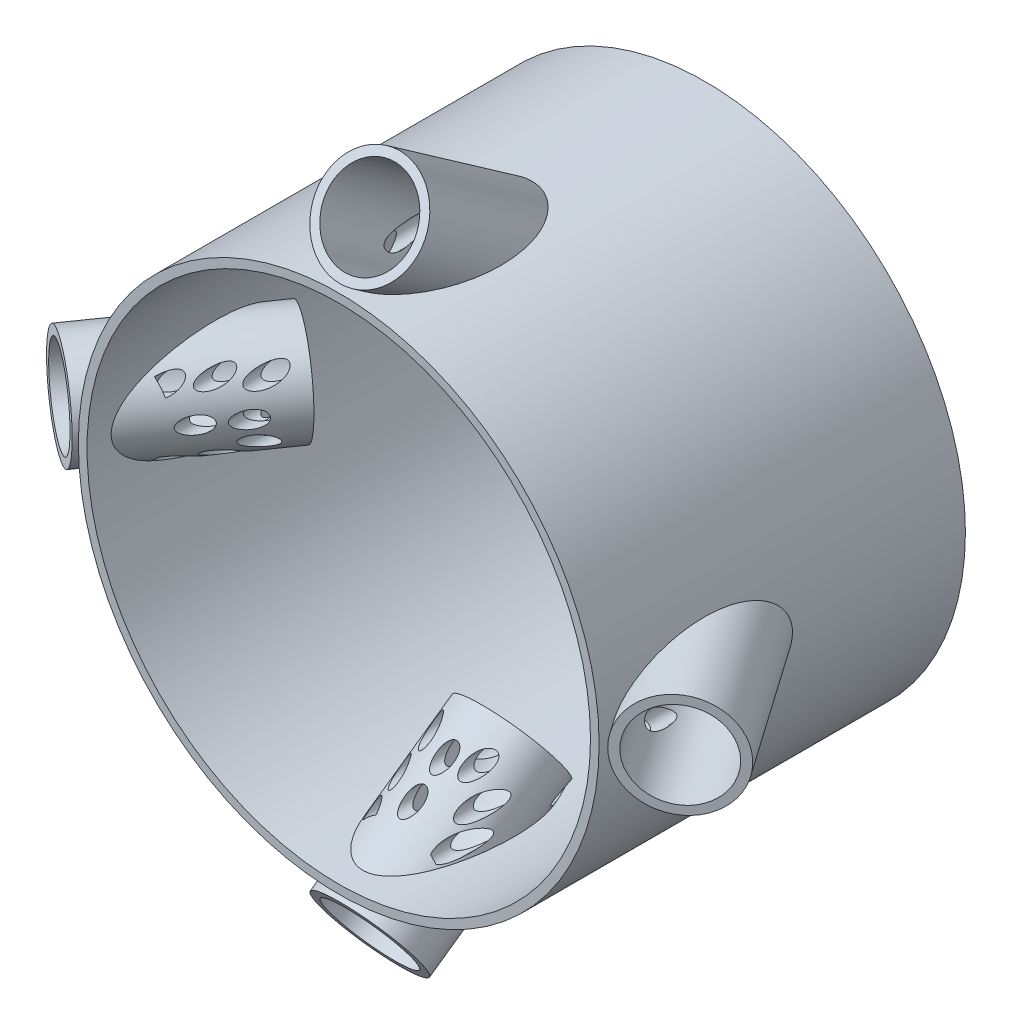
from build123d import *

# Parameters (mm, degrees)
SKETCH2_R                = 300
SKETCH2_R_2              = 290
BOSS_EXTRUDE1_DEPTH      = 405
BOSS_EXTRUDE1_DEPTH_BACK = 17
SKETCH7_R                = 60
SKETCH7_R_2              = 50
BOSS_EXTRUDE2_DEPTH      = 320
SKETCH8_R                = 60
SKETCH8_R_2              = 50
CUT_EXTRUDE1_DEPTH       = 120
SKETCH9_R                = 50
CUT_EXTRUDE2_DEPTH       = 1650
SKETCH10_R               = 60
SKETCH10_R_2             = 50
BOSS_EXTRUDE3_DEPTH      = 320
SKETCH16_R               = 60
SKETCH16_R_2             = 50
BOSS_EXTRUDE4_DEPTH      = 320
SKETCH17_R               = 60
SKETCH17_R_2             = 50
CUT_EXTRUDE3_DEPTH       = 120
SKETCH18_R               = 50
CUT_EXTRUDE4_DEPTH       = 600
SKETCH19_R               = 50
CUT_EXTRUDE5_DEPTH       = 600
SKETCH20_R               = 60
SKETCH20_R_2             = 50
BOSS_EXTRUDE5_DEPTH      = 320
SKETCH21_R               = 60
SKETCH21_R_2             = 50
BOSS_EXTRUDE6_DEPTH      = 120
SKETCH22_R               = 50
CUT_EXTRUDE6_DEPTH       = 733
SKETCH23_R               = 60
SKETCH23_R_2             = 50
CUT_EXTRUDE7_DEPTH       = 120
SKETCH24_R               = 60
SKETCH24_R_2             = 50
CUT_EXTRUDE8_DEPTH       = 120
SKETCH25_R               = 10
SKETCH25_R_2             = 8.952024114
CUT_EXTRUDE9_DEPTH       = 336


with BuildPart() as part:
    # Sketch2 → Boss-Extrude1 (new body, two sides)
    with BuildSketch(Plane.XY) as boss_extrude1_sk:
        Circle(SKETCH2_R)
        Circle(SKETCH2_R_2, mode=Mode.SUBTRACT)
    extrude(amount=BOSS_EXTRUDE1_DEPTH)
    extrude(boss_extrude1_sk.sketch, amount=-BOSS_EXTRUDE1_DEPTH_BACK)

    # Sketch7 → Boss-Extrude2 (add)
    with BuildSketch(Plane(origin=(-107.600608248, 0, 153.669594193), x_dir=(0.819152044, 0, 0.573576436), z_dir=(-0.573576436, 0, 0.819152044))):
        with Locations((-81.211008345, 0)):
            Circle(SKETCH7_R)
        with Locations((-81.211008345, 0)):
            Circle(SKETCH7_R_2, mode=Mode.SUBTRACT)
    extrude(amount=BOSS_EXTRUDE2_DEPTH)

    # Sketch8 → Cut-Extrude1 (cut)
    with BuildSketch(Plane(origin=(-107.600608248, 0, 153.669594193), x_dir=(0.819152044, 0, 0.573576436), z_dir=(-0.573576436, 0, 0.819152044))):
        with Locations((-81.211008345, 0)):
            Circle(SKETCH8_R)
        with Locations((-81.211008345, 0)):
            Circle(SKETCH8_R_2, mode=Mode.SUBTRACT)
    extrude(amount=CUT_EXTRUDE1_DEPTH, mode=Mode.SUBTRACT)

    # Sketch9 → Cut-Extrude2 (cut)
    with BuildSketch(Plane(origin=(-107.600608248, 0, 153.669594193), x_dir=(0.819152044, 0, 0.573576436), z_dir=(-0.573576436, 0, 0.819152044))):
        with Locations((-81.211008345, 0)):
            Circle(SKETCH9_R)
    extrude(amount=CUT_EXTRUDE2_DEPTH, mode=Mode.SUBTRACT)

    # Sketch10 → Boss-Extrude3 (add)
    with BuildSketch(Plane(origin=(107.600608248, 0, 153.669594193), x_dir=(-0.819152044, 0, 0.573576436), z_dir=(-0.573576436, 0, -0.819152044))):
        with Locations((-81.211008345, 0)):
            Circle(SKETCH10_R)
        with Locations((-81.211008345, 0)):
            Circle(SKETCH10_R_2, mode=Mode.SUBTRACT)
    extrude(amount=-BOSS_EXTRUDE3_DEPTH)

    # Sketch16 → Boss-Extrude4 (add)
    with BuildSketch(Plane(origin=(0, -107.600608369, 153.669594367), x_dir=(0, 0.819152044, 0.573576436), z_dir=(0, 0.573576436, -0.819152044))):
        with Locations((-81.211008196, 0)):
            Circle(SKETCH16_R)
        with Locations((-81.211008196, 0)):
            Circle(SKETCH16_R_2, mode=Mode.SUBTRACT)
    extrude(amount=-BOSS_EXTRUDE4_DEPTH)

    # Sketch17 → Cut-Extrude3 (cut)
    with BuildSketch(Plane(origin=(0, -107.600608369, 153.669594367), x_dir=(0, 0.819152044, 0.573576436), z_dir=(0, 0.573576436, -0.819152044))):
        with Locations((-81.211008196, 0)):
            Circle(SKETCH17_R)
        with Locations((-81.211008196, 0)):
            Circle(SKETCH17_R_2, mode=Mode.SUBTRACT)
    extrude(amount=-CUT_EXTRUDE3_DEPTH, mode=Mode.SUBTRACT)

    # Sketch18 → Cut-Extrude4 (cut)
    with BuildSketch(Plane(origin=(0, -107.600608369, 153.669594367), x_dir=(0, 0.819152044, 0.573576436), z_dir=(0, 0.573576436, -0.819152044))):
        with Locations((-81.211008196, 0)):
            Circle(SKETCH18_R)
    extrude(amount=-CUT_EXTRUDE4_DEPTH, mode=Mode.SUBTRACT)

    # Sketch19 → Cut-Extrude5 (cut)
    with BuildSketch(Plane(origin=(107.600608248, 0, 153.669594193), x_dir=(-0.819152044, 0, 0.573576436), z_dir=(-0.573576436, 0, -0.819152044))):
        with Locations((-81.211008345, 0)):
            Circle(SKETCH19_R)
    extrude(amount=-CUT_EXTRUDE5_DEPTH, mode=Mode.SUBTRACT)

    # Sketch20 → Boss-Extrude5 (add)
    with BuildSketch(Plane(origin=(0, 107.600608369, 153.669594367), x_dir=(0, -0.819152044, 0.573576436), z_dir=(0, 0.573576436, 0.819152044))):
        with Locations((-81.211008196, 0)):
            Circle(SKETCH20_R)
        with Locations((-81.211008196, 0)):
            Circle(SKETCH20_R_2, mode=Mode.SUBTRACT)
    extrude(amount=BOSS_EXTRUDE5_DEPTH)

    # Sketch21 → Boss-Extrude6 (add)
    with BuildSketch(Plane(origin=(0, 107.600608369, 153.669594367), x_dir=(0, -0.819152044, 0.573576436), z_dir=(0, 0.573576436, 0.819152044))):
        with Locations((-81.211008196, 0)):
            Circle(SKETCH21_R)
        with Locations((-81.211008196, 0)):
            Circle(SKETCH21_R_2, mode=Mode.SUBTRACT)
    extrude(amount=BOSS_EXTRUDE6_DEPTH)

    # Sketch22 → Cut-Extrude6 (cut)
    with BuildSketch(Plane(origin=(0, 107.600608369, 153.669594367), x_dir=(0, -0.819152044, 0.573576436), z_dir=(0, 0.573576436, 0.819152044))):
        with Locations((-81.211008196, 0)):
            Circle(SKETCH22_R)
    extrude(amount=CUT_EXTRUDE6_DEPTH, mode=Mode.SUBTRACT)

    # Sketch23 → Cut-Extrude7 (cut)
    with BuildSketch(Plane(origin=(0, 107.600608369, 153.669594367), x_dir=(0, -0.819152044, 0.573576436), z_dir=(0, 0.573576436, 0.819152044))):
        with Locations((-81.211008196, 0)):
            Circle(SKETCH23_R)
        with Locations((-81.211008196, 0)):
            Circle(SKETCH23_R_2, mode=Mode.SUBTRACT)
    extrude(amount=CUT_EXTRUDE7_DEPTH, mode=Mode.SUBTRACT)

    # Sketch24 → Cut-Extrude8 (cut)
    with BuildSketch(Plane(origin=(107.600608248, 0, 153.669594193), x_dir=(-0.819152044, 0, 0.573576436), z_dir=(-0.573576436, 0, -0.819152044))):
        with Locations((-81.211008345, 0)):
            Circle(SKETCH24_R)
        with Locations((-81.211008345, 0)):
            Circle(SKETCH24_R_2, mode=Mode.SUBTRACT)
    extrude(amount=-CUT_EXTRUDE8_DEPTH, mode=Mode.SUBTRACT)

    # Sketch25 → Cut-Extrude9 (cut)
    with BuildSketch(Plane.XY):
        with Locations((0, 250.097173682)):
            Circle(SKETCH25_R)
        with Locations((36.92709947, 250.097173682)):
            Circle(SKETCH25_R_2)
        with Locations((-43.641117555, 250.097173682)):
            Circle(SKETCH25_R)
        with Locations((-26.856072342, 224.360104354)):
            Circle(SKETCH25_R)
        with Locations((-46.519733643, 273.994450106)):
            Circle(SKETCH25_R)
        with Locations((1, 276.683248051)):
            Circle(SKETCH25_R_2)
        with Locations((34.434879857, 273.994450106)):
            Circle(SKETCH25_R)
        with Locations((34.434879857, 224.360104354)):
            Circle(SKETCH25_R)
        with Locations((0, 224.360104354)):
            Circle(SKETCH25_R)
        with Locations((250.097173682, 0)):
            Circle(SKETCH25_R)
        with Locations((250.097173682, -36.92709947)):
            Circle(SKETCH25_R_2)
        with Locations((250.097173682, 43.641117555)):
            Circle(SKETCH25_R)
        with Locations((224.360104354, 26.856072342)):
            Circle(SKETCH25_R)
        with Locations((273.994450106, 46.519733643)):
            Circle(SKETCH25_R)
        with Locations((276.683248051, -1)):
            Circle(SKETCH25_R_2)
        with Locations((273.994450106, -34.434879857)):
            Circle(SKETCH25_R)
        with Locations((224.360104354, -34.434879857)):
            Circle(SKETCH25_R)
        with Locations((224.360104354, 0)):
            Circle(SKETCH25_R)
        with Locations((0, -250.097173682)):
            Circle(SKETCH25_R)
        with Locations((-36.92709947, -250.097173682)):
            Circle(SKETCH25_R_2)
        with Locations((43.641117555, -250.097173682)):
            Circle(SKETCH25_R)
        with Locations((26.856072342, -224.360104354)):
            Circle(SKETCH25_R)
        with Locations((46.519733643, -273.994450106)):
            Circle(SKETCH25_R)
        with Locations((-1, -276.683248051)):
            Circle(SKETCH25_R_2)
        with Locations((-34.434879857, -273.994450106)):
            Circle(SKETCH25_R)
        with Locations((-34.434879857, -224.360104354)):
            Circle(SKETCH25_R)
        with Locations((0, -224.360104354)):
            Circle(SKETCH25_R)
        with Locations((-250.097173682, 0)):
            Circle(SKETCH25_R)
        with Locations((-250.097173682, 36.92709947)):
            Circle(SKETCH25_R_2)
        with Locations((-250.097173682, -43.641117555)):
            Circle(SKETCH25_R)
        with Locations((-224.360104354, -26.856072342)):
            Circle(SKETCH25_R)
        with Locations((-273.994450106, -46.519733643)):
            Circle(SKETCH25_R)
        with Locations((-276.683248051, 1)):
            Circle(SKETCH25_R_2)
        with Locations((-273.994450106, 34.434879857)):
            Circle(SKETCH25_R)
        with Locations((-224.360104354, 34.434879857)):
            Circle(SKETCH25_R)
        with Locations((-224.360104354, 0)):
            Circle(SKETCH25_R)
    extrude(amount=CUT_EXTRUDE9_DEPTH, mode=Mode.SUBTRACT)


solid = part.part
